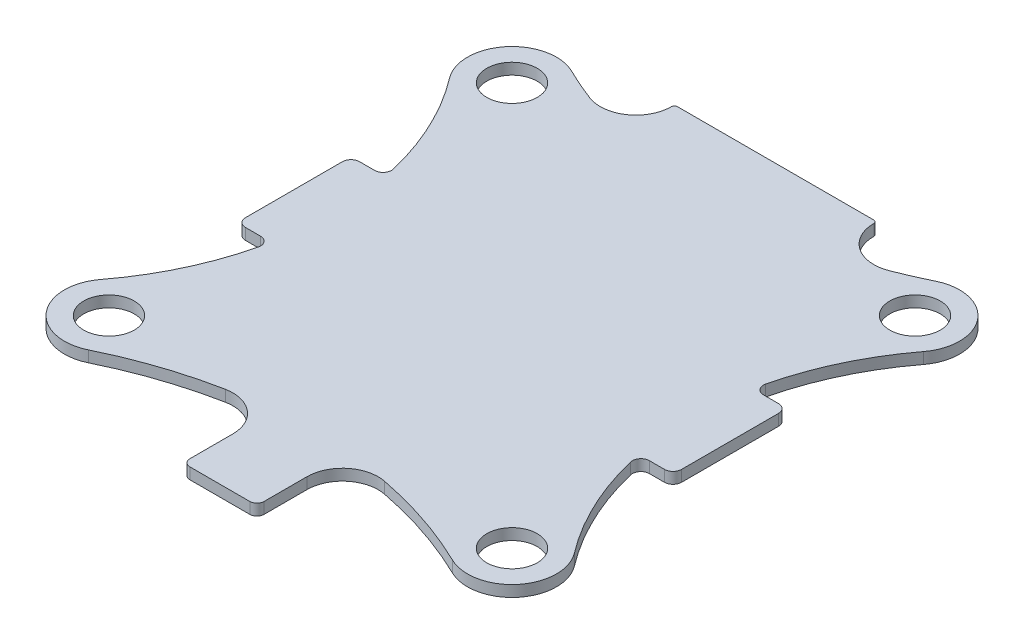
from build123d import *

# Parameters (mm, degrees)
SKETCH1_R           = 2.25
BOSS_EXTRUDE2_DEPTH = 1


with BuildPart() as part:
    # Sketch1 → Boss-Extrude2 (new body)
    with BuildSketch(Plane(origin=(0, 0, 0), x_dir=(1, 0, 0), z_dir=(0, 1, 0))):
        with BuildLine():
            Line((-17.330956316, -5.08), (-18.669, -5.08))
            ThreePointArc((-18.669, -5.08), (-19.207815367, -4.856815367), (-19.431, -4.318))
            Line((-19.431, -4.318), (-19.431, 4.318))
            ThreePointArc((-19.431, 4.318), (-19.207815367, 4.856815367), (-18.669, 5.08))
            Line((-18.669, 5.08), (-17.330956316, 5.08))
            ThreePointArc((-17.330956316, 5.08), (-16.732344988, 5.370503999), (-16.590161442, 6.020513179))
            ThreePointArc((-16.590161442, 6.020513179), (-18.359695736, 11.0243031), (-21.119367367, 15.557886415))
            ThreePointArc((-21.119367367, 15.557886415), (-21.028176895, 20.478529347), (-16.219689319, 21.527094936))
            ThreePointArc((-16.219689319, 21.527094936), (-14.791805557, 20.867380989), (-13.337157819, 20.268987731))
            ThreePointArc((-13.337157819, 20.268987731), (-10.39690266, 20.611451573), (-9.017, 23.230277748))
            Line((-9.017, 23.230277748), (-9.017, 23.241))
            ThreePointArc((-9.017, 23.241), (-8.942605122, 23.420605122), (-8.763, 23.495))
            Line((-8.763, 23.495), (8.763, 23.495))
            ThreePointArc((8.763, 23.495), (8.942605122, 23.420605122), (9.017, 23.241))
            Line((9.017, 23.241), (9.017, 23.230277748))
            ThreePointArc((9.017, 23.230277748), (10.39690266, 20.611451573), (13.337157819, 20.268987731))
            ThreePointArc((13.337157819, 20.268987731), (14.791805557, 20.867380989), (16.219689319, 21.527094936))
            ThreePointArc((16.219689319, 21.527094936), (21.028176895, 20.478529347), (21.119367367, 15.557886415))
            ThreePointArc((21.119367367, 15.557886415), (18.359695736, 11.0243031), (16.590161442, 6.020513179))
            ThreePointArc((16.590161442, 6.020513179), (16.732344988, 5.370503999), (17.330956316, 5.08))
            Line((17.330956316, 5.08), (18.669, 5.08))
            ThreePointArc((18.669, 5.08), (19.207815367, 4.856815367), (19.431, 4.318))
            Line((19.431, 4.318), (19.431, -4.318))
            ThreePointArc((19.431, -4.318), (19.207815367, -4.856815367), (18.669, -5.08))
            Line((18.669, -5.08), (17.330956316, -5.08))
            ThreePointArc((17.330956316, -5.08), (16.732344988, -5.370503999), (16.590161442, -6.020513179))
            ThreePointArc((16.590161442, -6.020513179), (18.359695736, -11.0243031), (21.119367367, -15.557886415))
            ThreePointArc((21.119367367, -15.557886415), (21.028176895, -20.478529347), (16.219689319, -21.527094936))
            ThreePointArc((16.219689319, -21.527094936), (11.752669663, -19.697385754), (7.085365092, -18.465164862))
            ThreePointArc((7.085365092, -18.465164862), (4.458452771, -19.130602125), (3.302, -21.581335094))
            Line((3.302, -21.581335094), (3.302, -25.4))
            ThreePointArc((3.302, -25.4), (3.116012806, -25.849012806), (2.667, -26.035))
            Line((2.667, -26.035), (-2.667, -26.035))
            ThreePointArc((-2.667, -26.035), (-3.116012806, -25.849012806), (-3.302, -25.4))
            Line((-3.302, -25.4), (-3.302, -21.581335094))
            ThreePointArc((-3.302, -21.581335094), (-4.458452771, -19.130602125), (-7.085365092, -18.465164862))
            ThreePointArc((-7.085365092, -18.465164862), (-11.752669663, -19.697385754), (-16.219689319, -21.527094936))
            ThreePointArc((-16.219689319, -21.527094936), (-21.028176895, -20.478529347), (-21.119367367, -15.557886415))
            ThreePointArc((-21.119367367, -15.557886415), (-18.359695736, -11.0243031), (-16.590161442, -6.020513179))
            ThreePointArc((-16.590161442, -6.020513179), (-16.732344988, -5.370503999), (-17.330956316, -5.08))
        make_face()
        with Locations((-17.960512242, -17.960512242)):
            Circle(SKETCH1_R, mode=Mode.SUBTRACT)
        with Locations((17.960512242, -17.960512242)):
            Circle(SKETCH1_R, mode=Mode.SUBTRACT)
        with Locations((17.960512242, 17.960512242)):
            Circle(SKETCH1_R, mode=Mode.SUBTRACT)
        with Locations((-17.960512242, 17.960512242)):
            Circle(SKETCH1_R, mode=Mode.SUBTRACT)
    extrude(amount=BOSS_EXTRUDE2_DEPTH)


solid = part.part
